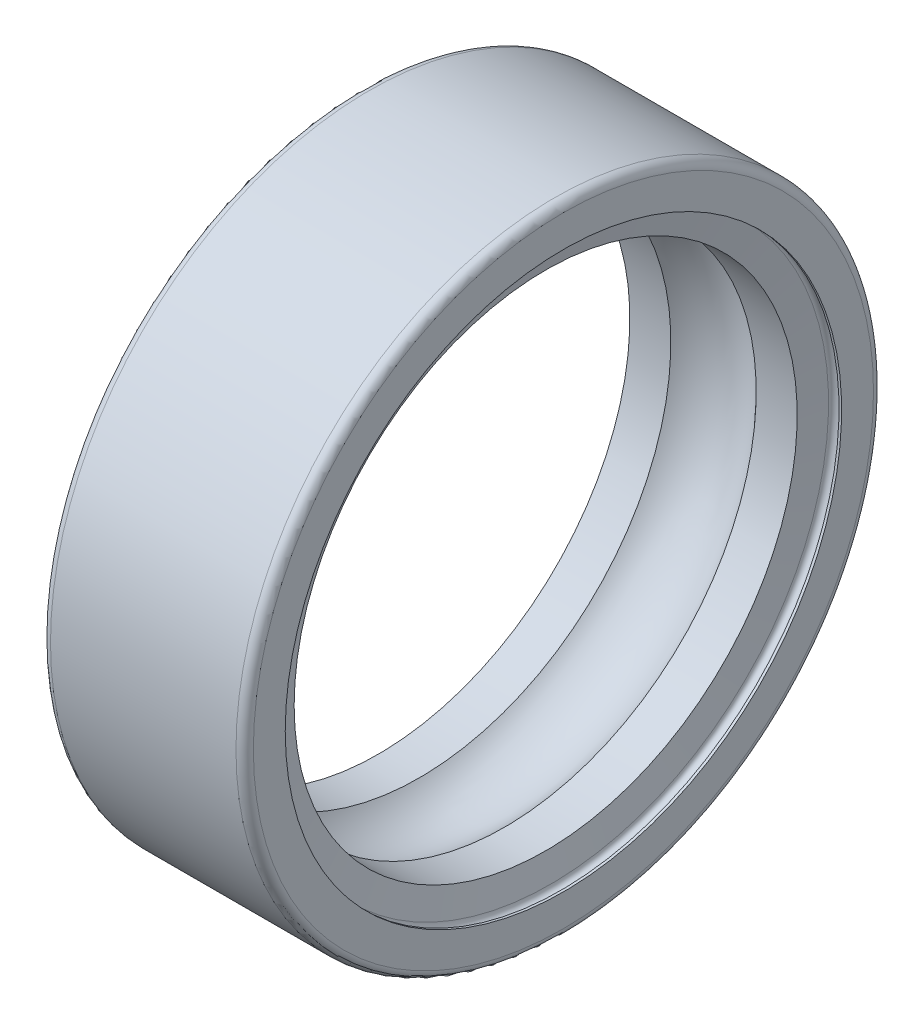
from build123d import *


with BuildPart() as part:
    # Skizze1 → Rotation1 (revolve)
    with BuildSketch(Plane.XY):
        with BuildLine():
            Line((0, 9.6), (0.09, 9.6))
            ThreePointArc((0.09, 9.6), (0.27, 9.78), (0.45, 9.6))
            Line((0.45, 9.6), (0.612220822, 8.68))
            Line((0.612220822, 8.68), (2.027131964, 8.68))
            ThreePointArc((2.027131964, 8.68), (3.5, 9.3345), (4.972868036, 8.68))
            Line((4.972868036, 8.68), (6.387779178, 8.68))
            Line((6.387779178, 8.68), (6.55, 9.6))
            ThreePointArc((6.55, 9.6), (6.73, 9.780000009), (6.91, 9.6))
            Line((6.91, 9.6), (7, 9.6))
            Line((7, 9.6), (7, 10.7))
            ThreePointArc((7, 10.7), (6.912132034, 10.912132034), (6.7, 11))
            Line((6.7, 11), (0.3, 11))
            ThreePointArc((0.3, 11), (0.087867966, 10.912132034), (0, 10.7))
            Line((0, 10.7), (0, 9.6))
        make_face()
    revolve(axis=Axis((50, 0, 0), (-1, 0, 0)))


solid = part.part
